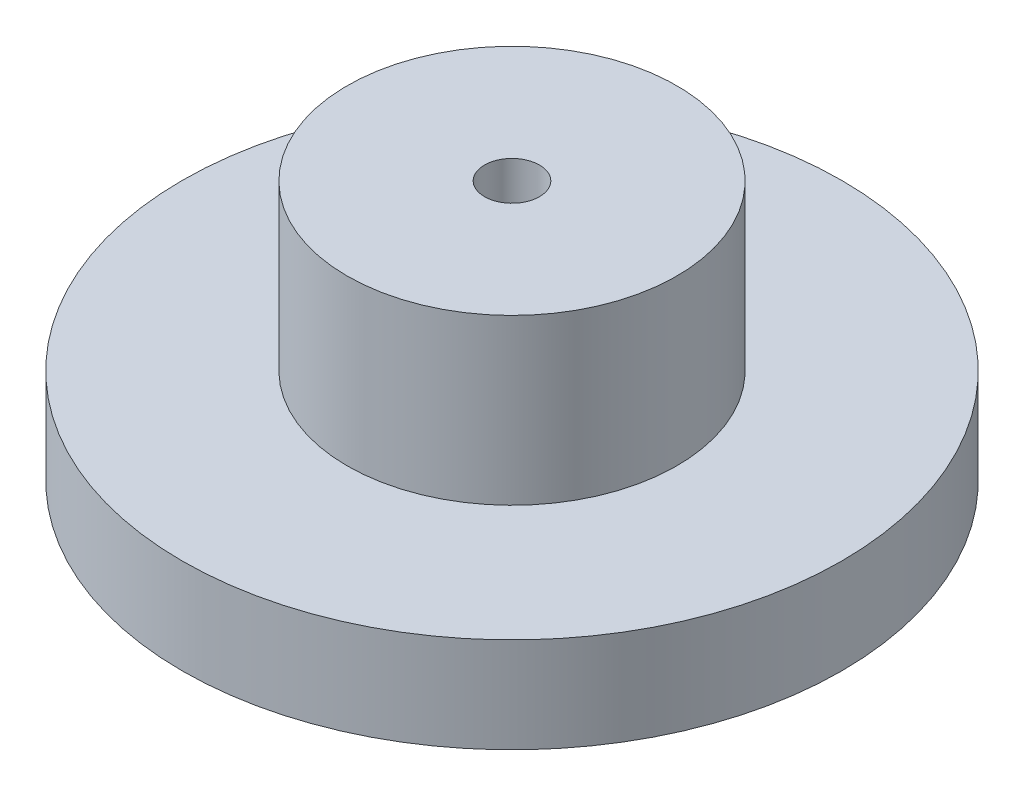
from build123d import *

# Parameters (mm, degrees)
ESQUISSE1_R             = 38.1
BOSS_EXTRU_1_DEPTH      = 11
ESQUISSE2_R             = 19.05
BOSS_EXTRU_2_DEPTH      = 19
ESQUISSE3_R             = 3.175
ENL_V_MAT_EXTRU_1_DEPTH = 31


with BuildPart() as part:
    # Esquisse1 → Boss.-Extru.1 (new body)
    with BuildSketch(Plane(origin=(0, 0, 0), x_dir=(1, 0, 0), z_dir=(0, 1, 0))):
        Circle(ESQUISSE1_R)
    extrude(amount=BOSS_EXTRU_1_DEPTH)

    # Esquisse2 → Boss.-Extru.2 (add)
    with BuildSketch(Plane(origin=(0, 11, 0), x_dir=(1, 0, 0), z_dir=(0, 1, 0))):
        Circle(ESQUISSE2_R)
    extrude(amount=BOSS_EXTRU_2_DEPTH)

    # Esquisse3 → Enlèv. mat.-Extru.1 (cut, through all)
    with BuildSketch(Plane(origin=(0, 30, 0), x_dir=(1, 0, 0), z_dir=(0, 1, 0))):
        Circle(ESQUISSE3_R)
    extrude(amount=-ENL_V_MAT_EXTRU_1_DEPTH, mode=Mode.SUBTRACT)


solid = part.part
